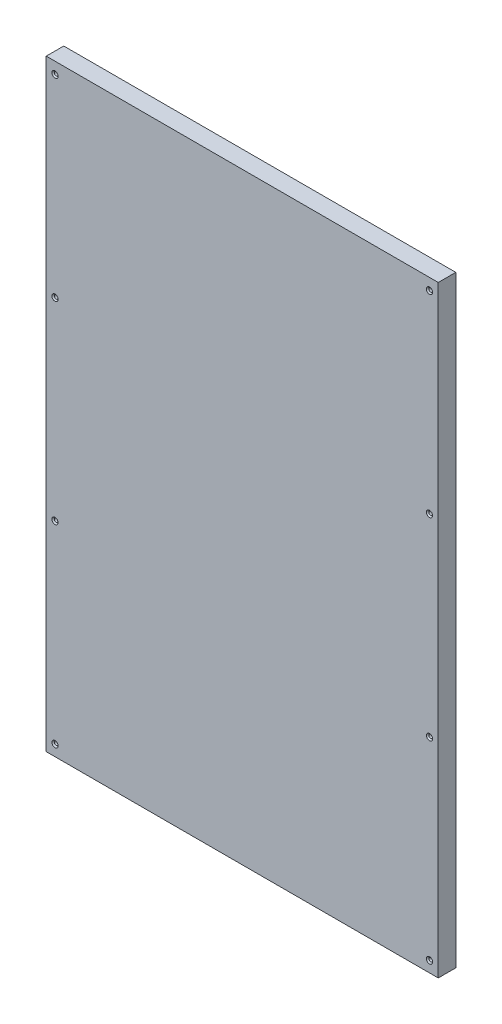
from build123d import *

# Parameters (mm, degrees)
SKETCH1_W                                         = 357.94
SKETCH1_H                                         = 550
BOSS_EXTRUDE1_DEPTH                               = 16
CSK_FOR_4_FLAT_HEAD_MACHINE_SCREW_100_D           = 3.2639
CSK_FOR_4_FLAT_HEAD_MACHINE_SCREW_100_DEPTH       = 16
CSK_FOR_4_FLAT_HEAD_MACHINE_SCREW_100_CSINK_D     = 5.715
CSK_FOR_4_FLAT_HEAD_MACHINE_SCREW_100_CSINK_ANGLE = 100
LPATTERN1_COUNT                                   = 4
LPATTERN1_PITCH                                   = 176.5
MIRROR1_COPY_1_D                                  = 3.2639
MIRROR1_COPY_1_DEPTH                              = 16
MIRROR1_COPY_1_CSINK_D                            = 5.715
MIRROR1_COPY_1_CSINK_ANGLE                        = 100
MIRROR1_COPY_2_D                                  = 3.2639
MIRROR1_COPY_2_DEPTH                              = 16
MIRROR1_COPY_2_CSINK_D                            = 5.715
MIRROR1_COPY_2_CSINK_ANGLE                        = 100
MIRROR1_COPY_3_D                                  = 3.2639
MIRROR1_COPY_3_DEPTH                              = 16
MIRROR1_COPY_3_CSINK_D                            = 5.715
MIRROR1_COPY_3_CSINK_ANGLE                        = 100


with BuildPart() as part:
    # Sketch1 → Boss-Extrude1 (new body)
    with BuildSketch(Plane.XY):
        Rectangle(SKETCH1_W, SKETCH1_H)
    extrude(amount=BOSS_EXTRUDE1_DEPTH)

    # CSK for #4 Flat Head Machine Screw (100)1
    with Locations(Plane(origin=(-170.97, -265, 16), x_dir=(1, 0, 0), z_dir=(0, 0, 1))):
        with Locations((0, 0)):
            csk_for_4_flat_head_machine_screw_100 = CounterSinkHole(CSK_FOR_4_FLAT_HEAD_MACHINE_SCREW_100_D / 2, CSK_FOR_4_FLAT_HEAD_MACHINE_SCREW_100_CSINK_D / 2, depth=CSK_FOR_4_FLAT_HEAD_MACHINE_SCREW_100_DEPTH, counter_sink_angle=CSK_FOR_4_FLAT_HEAD_MACHINE_SCREW_100_CSINK_ANGLE)

    # LPattern1: CSK for #4 Flat Head Machine Screw (100)1 ×4
    with Locations(*[(0, i * LPATTERN1_PITCH, 0) for i in range(1, LPATTERN1_COUNT)]):
        add(csk_for_4_flat_head_machine_screw_100, mode=Mode.SUBTRACT)

    # Mirror1: CSK for #4 Flat Head Machine Screw (100)1 across plane
    add(csk_for_4_flat_head_machine_screw_100.mirror(Plane(origin=(0, 0, 0), x_dir=(0, 0, 1), z_dir=(1, 0, 0))), mode=Mode.SUBTRACT)

    # Mirror1 copy 1
    with Locations(Plane(origin=(170.97, -88.5, 16), x_dir=(-1, 0, 0), z_dir=(0, 0, 1))):
        with Locations((0, 0)):
            CounterSinkHole(MIRROR1_COPY_1_D / 2, MIRROR1_COPY_1_CSINK_D / 2, depth=MIRROR1_COPY_1_DEPTH, counter_sink_angle=MIRROR1_COPY_1_CSINK_ANGLE)

    # Mirror1 copy 2
    with Locations(Plane(origin=(170.97, 88, 16), x_dir=(-1, 0, 0), z_dir=(0, 0, 1))):
        with Locations((0, 0)):
            CounterSinkHole(MIRROR1_COPY_2_D / 2, MIRROR1_COPY_2_CSINK_D / 2, depth=MIRROR1_COPY_2_DEPTH, counter_sink_angle=MIRROR1_COPY_2_CSINK_ANGLE)

    # Mirror1 copy 3
    with Locations(Plane(origin=(170.97, 264.5, 16), x_dir=(-1, 0, 0), z_dir=(0, 0, 1))):
        with Locations((0, 0)):
            CounterSinkHole(MIRROR1_COPY_3_D / 2, MIRROR1_COPY_3_CSINK_D / 2, depth=MIRROR1_COPY_3_DEPTH, counter_sink_angle=MIRROR1_COPY_3_CSINK_ANGLE)


solid = part.part
